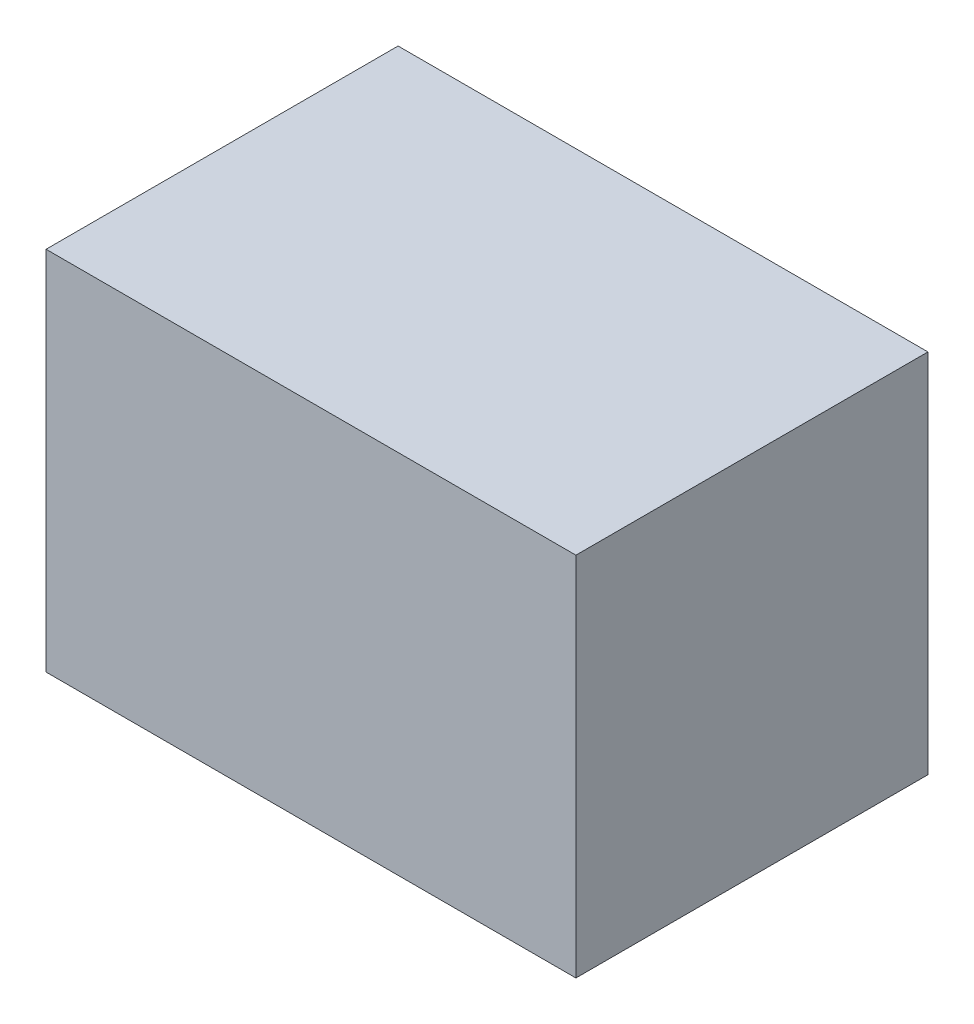
from build123d import *

# Parameters (mm, degrees)
SKETCH1_W           = 90.305541698
SKETCH1_H           = 62.411938084
BOSS_EXTRUDE1_DEPTH = 60


with BuildPart() as part:
    # Sketch1 → Boss-Extrude1 (new body)
    with BuildSketch(Plane.XY):
        Rectangle(SKETCH1_W, SKETCH1_H)
    extrude(amount=BOSS_EXTRUDE1_DEPTH)


solid = part.part
